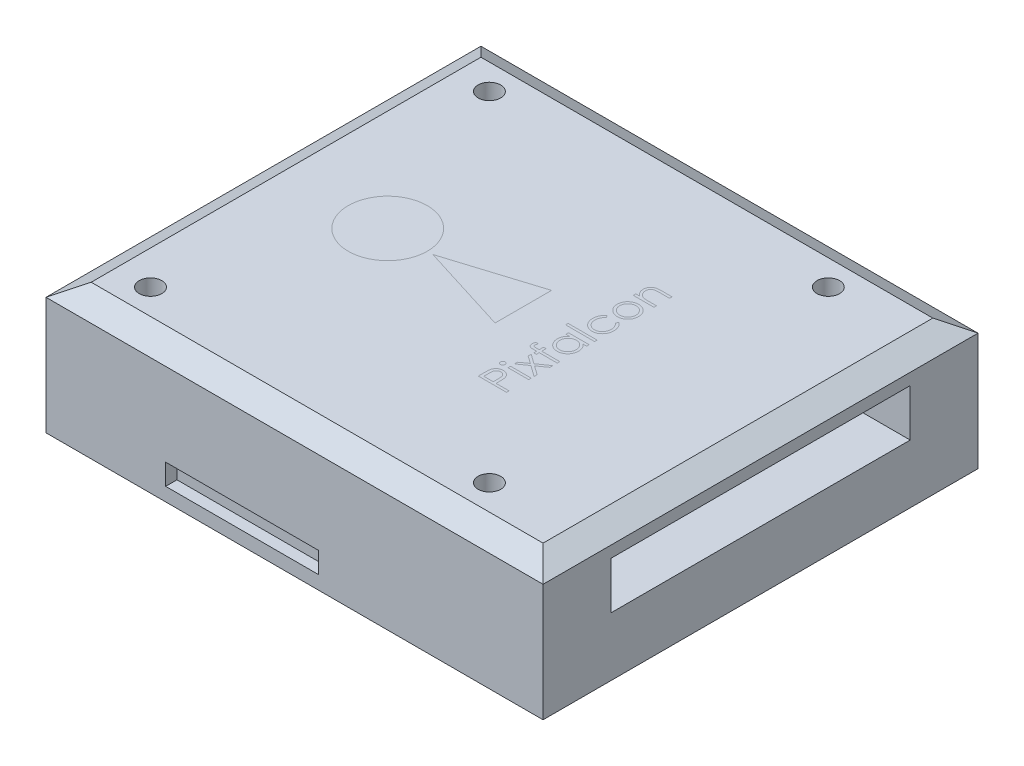
from build123d import *

# Parameters (mm, degrees)
SKETCH1_W             = 44
SKETCH1_H             = 38.5
BOSS_EXTRUDE1_DEPTH   = 12.7
CHAMFER1_SIZE         = 2
CHAMFER1_SIZE2        = 1.154700538
CHAMFER1_PART_2_SIZE  = 2
CHAMFER1_PART_2_SIZE2 = 1.154700538
SKETCH2_W             = 29
SKETCH2_H             = 3.71
CUT_EXTRUDE1_DEPTH    = 7.5
SKETCH3_W             = 26.5
SKETCH3_H             = 4.18
CUT_EXTRUDE2_DEPTH    = 7.5
SKETCH5_R             = 1
CUT_EXTRUDE3_DEPTH    = 2
SKETCH6_W             = 5.836145695
SKETCH6_H             = 2.652793498
SKETCH6_W_2           = 13.440820391
SKETCH6_H_2           = 3.537057997
CUT_EXTRUDE4_DEPTH    = 2
SKETCH7_W             = 13.529246841
SKETCH7_H             = 1.856955449
CUT_EXTRUDE5_DEPTH    = 1


with BuildPart() as part:
    # Sketch1 → Boss-Extrude1 (new body)
    with BuildSketch(Plane(origin=(0, 0, 0), x_dir=(1, 0, 0), z_dir=(0, 1, 0))):
        Rectangle(SKETCH1_W, SKETCH1_H)
    extrude(amount=BOSS_EXTRUDE1_DEPTH)

    # Chamfer1
    chamfer1_edges = [part.edges().sort_by_distance(p)[0] for p in [
        (-22, 12.7, 0),
        (0, 12.7, 19.25),
        (22, 12.7, 0),
        (0, 12.7, -19.25),
    ]]
    chamfer1_side = [part.faces().sort_by_distance(p)[0] for p in [
        (0, 12.7, 0),
    ]]
    chamfer(chamfer1_edges, length=CHAMFER1_SIZE, length2=CHAMFER1_SIZE2, reference=chamfer1_side[0])

    # Chamfer1 part 2
    chamfer1_part_2_edges = [part.edges().sort_by_distance(p)[0] for p in [
        (0, 0, 19.25),
        (-22, 0, 0),
        (0, 0, -19.25),
        (22, 0, 0),
    ]]
    chamfer1_part_2_side = [part.faces().sort_by_distance(p)[0] for p in [
        (0, 0, 0),
    ]]
    chamfer(chamfer1_part_2_edges, length=CHAMFER1_PART_2_SIZE, length2=CHAMFER1_PART_2_SIZE2, reference=chamfer1_part_2_side[0])

    # Sketch2 → Cut-Extrude1 (cut)
    with BuildSketch(Plane.ZY.offset(22)):
        with Locations((0, 8.205)):
            Rectangle(SKETCH2_W, SKETCH2_H)
    extrude(amount=-CUT_EXTRUDE1_DEPTH, mode=Mode.SUBTRACT)

    # Sketch3 → Cut-Extrude2 (cut)
    with BuildSketch(Plane(origin=(22, 0, 0), x_dir=(0, 0, -1), z_dir=(1, 0, 0))):
        with Locations((0, 8.44)):
            Rectangle(SKETCH3_W, SKETCH3_H)
    extrude(amount=-CUT_EXTRUDE2_DEPTH, mode=Mode.SUBTRACT)

    # Sketch5 → Cut-Extrude3 (cut)
    with BuildSketch(Plane(origin=(0, 12.7, 0), x_dir=(1, 0, 0), z_dir=(0, 1, 0))):
        with Locations((-17, -15)):
            Circle(SKETCH5_R)
        with Locations((-17, 15)):
            Circle(SKETCH5_R)
        with Locations((13, 15)):
            Circle(SKETCH5_R)
        with Locations((13, -15)):
            Circle(SKETCH5_R)
    extrude(amount=-CUT_EXTRUDE3_DEPTH, mode=Mode.SUBTRACT)

    # Sketch6 → Cut-Extrude4 (cut)
    with BuildSketch(Plane(origin=(0, 0, -19.25), x_dir=(-1, 0, 0), z_dir=(0, 0, -1))):
        with Locations((-2.166448024, 3.719313114)):
            Rectangle(SKETCH6_W, SKETCH6_H)
        with Locations((9.726909494, 7.919569487)):
            Rectangle(SKETCH6_W_2, SKETCH6_H_2)
    extrude(amount=-CUT_EXTRUDE4_DEPTH, mode=Mode.SUBTRACT)

    # Sketch7 → Cut-Extrude5 (cut)
    with BuildSketch(Plane.XY.offset(19.25)):
        with Locations((-4.642388622, 3.277180865)):
            Rectangle(SKETCH7_W, SKETCH7_H)
    extrude(amount=-CUT_EXTRUDE5_DEPTH, mode=Mode.SUBTRACT)


solid = part.part
